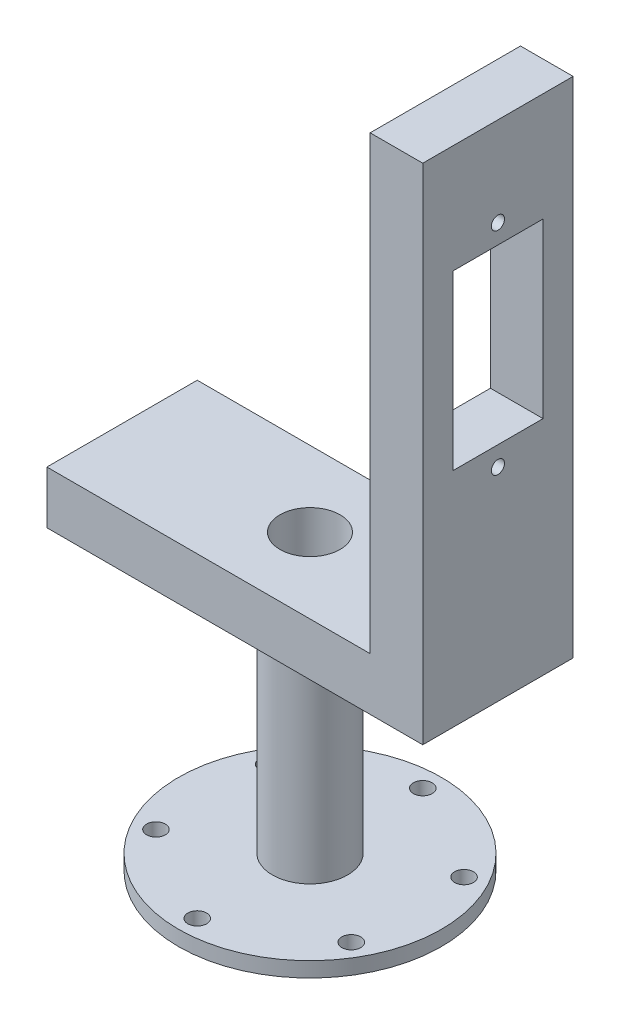
from build123d import *

# Parameters (mm, degrees)
SKETCH1_R               = 17.5
BOSS_EXTRUDE1_DEPTH     = 2
SKETCH2_R               = 1.25
CUT_EXTRUDE1_DEPTH      = 5
CIRPATTERN1_COUNT       = 6
SKETCH3_R               = 5
BOSS_EXTRUDE2_DEPTH     = 30
SKETCH4_W               = 50
SKETCH4_H               = 20
BOSS_EXTRUDE3_DEPTH     = 7
SKETCH5_W               = 7
SKETCH5_H               = 20
BOSS_EXTRUDE4_DEPTH     = 60
SKETCH6_R               = 0.875
CUT_EXTRUDE2_DEPTH      = 7
SKETCH7_W               = 12
SKETCH7_H               = 23
CUT_EXTRUDE3_DEPTH      = 7
SKETCH8_R               = 4
CUT_EXTRUDE4_DEPTH      = 32
CUT_EXTRUDE4_DEPTH_BACK = 7


with BuildPart() as part:
    # Sketch1 → Boss-Extrude1 (new body)
    with BuildSketch(Plane(origin=(0, 0, 0), x_dir=(1, 0, 0), z_dir=(0, 1, 0))):
        Circle(SKETCH1_R)
    extrude(amount=BOSS_EXTRUDE1_DEPTH)

    # Sketch2 → Cut-Extrude1 (cut)
    with BuildSketch(Plane(origin=(0, 2, 0), x_dir=(1, 0, 0), z_dir=(0, 1, 0))):
        with Locations((0, 15)):
            Circle(SKETCH2_R)
    cut_extrude1 = extrude(amount=-CUT_EXTRUDE1_DEPTH, mode=Mode.SUBTRACT)

    # CirPattern1: Cut-Extrude1 ×6 about axis
    cirpattern1_axis = Axis((0, 0, 0), (0, 1, 0))
    for i in range(1, CIRPATTERN1_COUNT):
        add(cut_extrude1.rotate(cirpattern1_axis, i * 360 / CIRPATTERN1_COUNT), mode=Mode.SUBTRACT)

    # Sketch3 → Boss-Extrude2 (add)
    with BuildSketch(Plane(origin=(0, 2, 0), x_dir=(1, 0, 0), z_dir=(0, 1, 0))):
        Circle(SKETCH3_R)
    extrude(amount=BOSS_EXTRUDE2_DEPTH)

    # Sketch4 → Boss-Extrude3 (add)
    with BuildSketch(Plane(origin=(0, 32, 0), x_dir=(1, 0, 0), z_dir=(0, 1, 0))):
        Rectangle(SKETCH4_W, SKETCH4_H)
    extrude(amount=BOSS_EXTRUDE3_DEPTH)

    # Sketch5 → Boss-Extrude4 (add)
    with BuildSketch(Plane(origin=(0, 39, 0), x_dir=(1, 0, 0), z_dir=(0, 1, 0))):
        with Locations((21.5, 0)):
            Rectangle(SKETCH5_W, SKETCH5_H)
    extrude(amount=BOSS_EXTRUDE4_DEPTH)

    # Sketch6 → Cut-Extrude2 (cut)
    with BuildSketch(Plane.ZY.offset(-18)):
        with Locations((0, 87.15)):
            Circle(SKETCH6_R)
        with Locations((0, 59)):
            Circle(SKETCH6_R)
    extrude(amount=-CUT_EXTRUDE2_DEPTH, mode=Mode.SUBTRACT)

    # Sketch7 → Cut-Extrude3 (cut)
    with BuildSketch(Plane.ZY.offset(-18)):
        with Locations((0, 73.075)):
            Rectangle(SKETCH7_W, SKETCH7_H)
    extrude(amount=-CUT_EXTRUDE3_DEPTH, mode=Mode.SUBTRACT)

    # Sketch8 → Cut-Extrude4 (cut, two sides)
    with BuildSketch(Plane(origin=(0, 32, 0), x_dir=(-1, 0, 0), z_dir=(0, -1, 0))) as cut_extrude4_sk:
        Circle(SKETCH8_R)
    extrude(amount=CUT_EXTRUDE4_DEPTH, mode=Mode.SUBTRACT)
    extrude(cut_extrude4_sk.sketch, amount=-CUT_EXTRUDE4_DEPTH_BACK, mode=Mode.SUBTRACT)


solid = part.part
